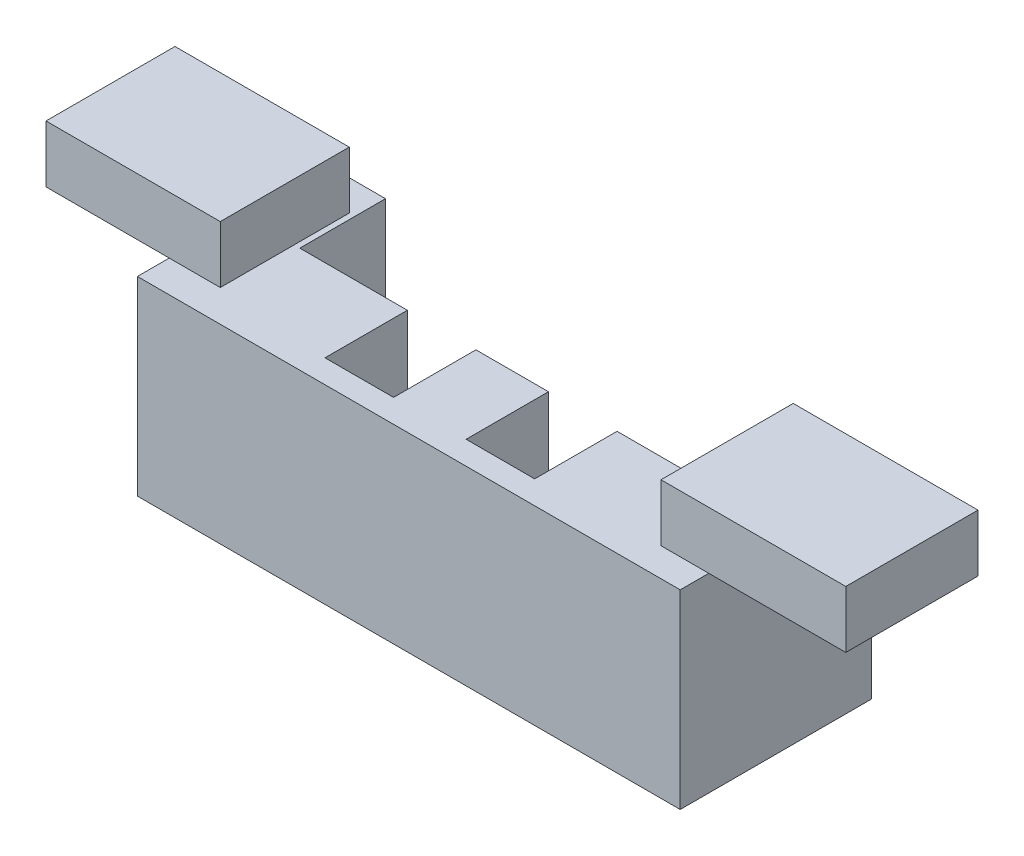
from build123d import *

# Parameters (mm, degrees)
SKETCH1_W           = 48.26
SKETCH1_H           = 17.018
BOSS_EXTRUDE1_DEPTH = 16.9164
SKETCH3_W           = 38.503555909
SKETCH3_H           = 15.229875851
CUT_EXTRUDE1_DEPTH  = 7.62
SKETCH4_W           = 6.096
SKETCH4_H           = 14.944038535
CUT_EXTRUDE2_DEPTH  = 15.24
SKETCH5_W           = 15.494422394
SKETCH5_H           = 11.468029568
SKETCH5_W_2         = 16.429120729
SKETCH5_H_2         = 11.755629056
BOSS_EXTRUDE2_DEPTH = 5.08


with BuildPart() as part:
    # Sketch1 → Boss-Extrude1 (new body)
    with BuildSketch(Plane(origin=(0, 0, 0), x_dir=(1, 0, 0), z_dir=(0, 1, 0))):
        with Locations((24.13, 8.509)):
            Rectangle(SKETCH1_W, SKETCH1_H)
    extrude(amount=BOSS_EXTRUDE1_DEPTH)

    # Sketch3 → Cut-Extrude1 (cut)
    with BuildSketch(Plane(origin=(0, 0, -17.018), x_dir=(-1, 0, 0), z_dir=(0, 0, -1))):
        with Locations((-24.292361965, 9.301462074)):
            Rectangle(SKETCH3_W, SKETCH3_H)
    extrude(amount=-CUT_EXTRUDE1_DEPTH, mode=Mode.SUBTRACT)

    # Sketch4 → Cut-Extrude2 (cut)
    with BuildSketch(Plane(origin=(0, 1.686524149, 0), x_dir=(1, 0, 0), z_dir=(0, 1, 0))):
        with Locations((17.651266973, 9.545980733)):
            Rectangle(SKETCH4_W, SKETCH4_H)
        with Locations((30.19779462, 9.545980733)):
            Rectangle(SKETCH4_W, SKETCH4_H)
    extrude(amount=CUT_EXTRUDE2_DEPTH, mode=Mode.SUBTRACT)

    # Sketch5 → Boss-Extrude2 (add)
    with BuildSketch(Plane(origin=(0, 16.9164, 0), x_dir=(1, 0, 0), z_dir=(0, 1, 0))):
        with Locations((-3.20992629, 8.562924904)):
            Rectangle(SKETCH5_W, SKETCH5_H)
        with Locations((52.224874945, 8.41912516)):
            Rectangle(SKETCH5_W_2, SKETCH5_H_2)
    extrude(amount=BOSS_EXTRUDE2_DEPTH)


solid = part.part
